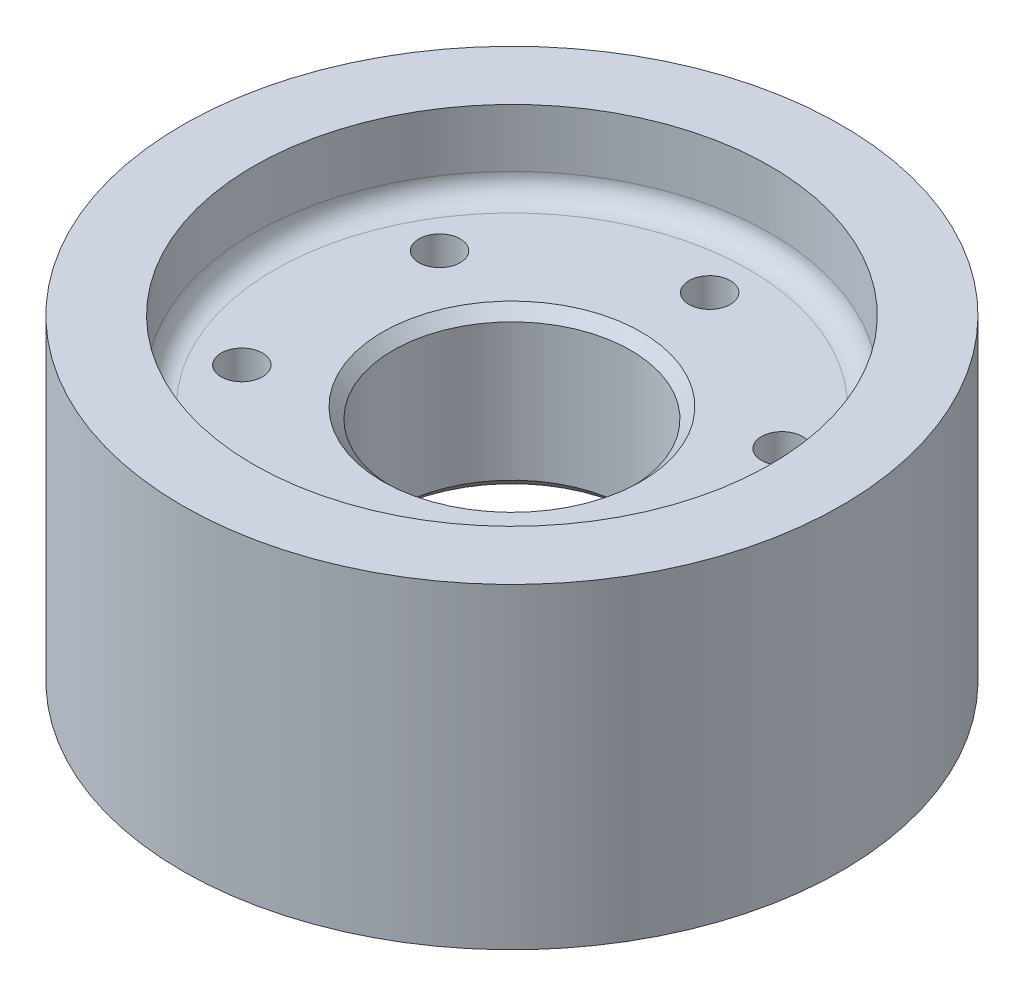
from build123d import *

# Parameters (mm, degrees)
SKETCH1_R              = 38.1
SKETCH1_R_2            = 14.3129
BOSS_EXTRUDE1_DEPTH    = 9.525
SKETCH2_R              = 39.6875
SKETCH2_R_2            = 31.115
BOSS_EXTRUDE2_DEPTH    = 19.05
F_10_CLEARANCE_HOLE1_D = 4.9784
CIRPATTERN1_COUNT      = 6
CHAMFER1_SIZE          = 1.27
FILLET2_R              = 2.54


with BuildPart() as part:
    # Sketch1 → Boss-Extrude1 (new body, symmetric)
    with BuildSketch(Plane(origin=(0, 0, 0), x_dir=(1, 0, 0), z_dir=(0, 1, 0))):
        Circle(SKETCH1_R)
        Circle(SKETCH1_R_2, mode=Mode.SUBTRACT)
    extrude(amount=BOSS_EXTRUDE1_DEPTH, both=True)

    # Sketch2 → Boss-Extrude2 (add, symmetric)
    with BuildSketch(Plane(origin=(0, 0, 0), x_dir=(1, 0, 0), z_dir=(0, 1, 0))):
        Circle(SKETCH2_R)
        Circle(SKETCH2_R_2, mode=Mode.SUBTRACT)
    extrude(amount=BOSS_EXTRUDE2_DEPTH, both=True)

    # #10 Clearance Hole1 (through all)
    with Locations(Plane(origin=(0, 9.525, 0), x_dir=(1, 0, 0), z_dir=(0, 1, 0))):
        with Locations((0, 23.8125)):
            f_10_clearance_hole1 = Hole(F_10_CLEARANCE_HOLE1_D / 2)

    # CirPattern1: #10 Clearance Hole1 ×6 about axis
    cirpattern1_axis = Axis((0, 0, 0), (0, 1, 0))
    for i in range(1, CIRPATTERN1_COUNT):
        add(f_10_clearance_hole1.rotate(cirpattern1_axis, i * 360 / CIRPATTERN1_COUNT), mode=Mode.SUBTRACT)

    # Chamfer1
    chamfer1_edges = [part.edges().sort_by_distance(p)[0] for p in [
        (-14.3129, -9.525, 0),
        (-14.3129, 9.525, 0),
    ]]
    chamfer(chamfer1_edges, length=CHAMFER1_SIZE)

    # Fillet2
    fillet2_edges = [part.edges().sort_by_distance(p)[0] for p in [
        (-31.115, 9.525, 0),
        (-31.115, -9.525, 0),
    ]]
    fillet(fillet2_edges, radius=FILLET2_R)


solid = part.part
